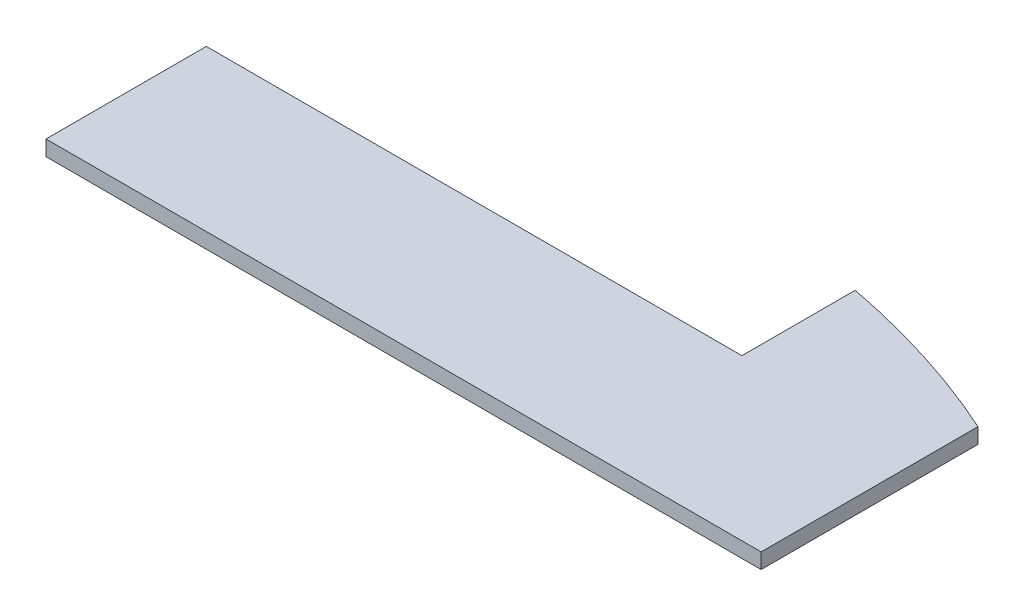
from build123d import *

# Parameters (mm, degrees)
BOSS_EXTRUDE1_DEPTH = 1.6


with BuildPart() as part:
    # Sketch1 → Boss-Extrude1 (new body)
    with BuildSketch(Plane(origin=(0, 0, 0), x_dir=(1, 0, 0), z_dir=(0, 1, 0))):
        with BuildLine():
            Line((0, 0), (74.5, 0))
            Line((74.5, 0), (74.5, 22.592093752))
            add(Edge.make_bspline(
                [(74.5, 22.592093752), (65.605442008, 26.625691322), (55.8, 28.490050428)],
                knots=[4.23030835, 4.23030835, 4.23030835, 4.496423735, 4.496423735, 4.496423735], degree=2, weights=[1, 0.991160878, 1]))
            Line((55.8, 28.490050428), (55.8, 16.7))
            Line((55.8, 16.7), (0, 16.7))
            Line((0, 16.7), (0, 0))
        make_face()
    extrude(amount=BOSS_EXTRUDE1_DEPTH)


solid = part.part
